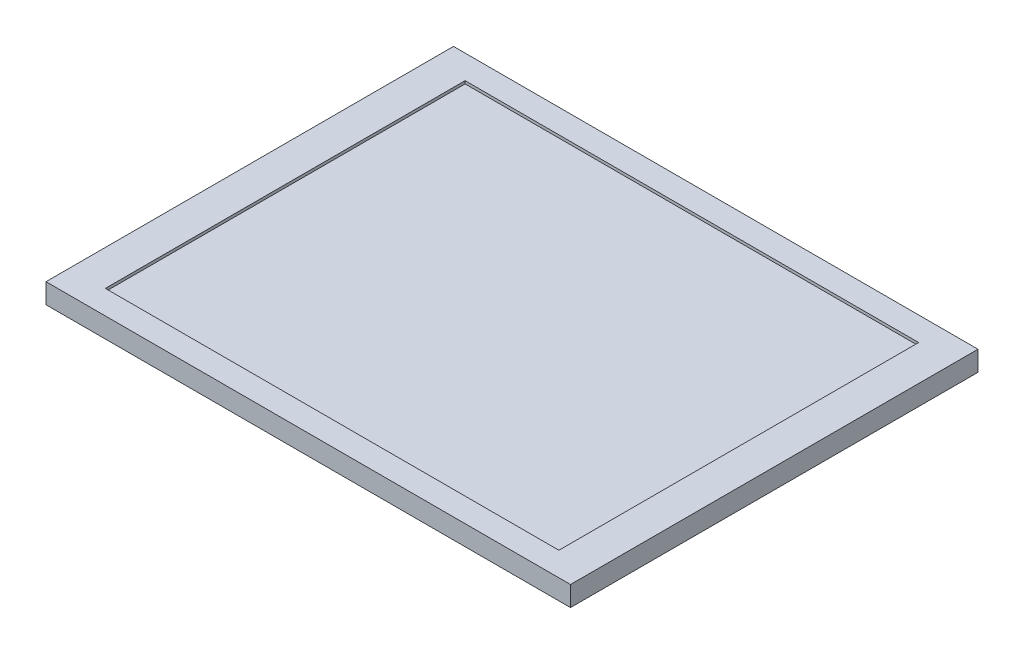
from build123d import *

# Parameters (mm, degrees)
ESBO_O1_W                = 278
ESBO_O1_H                = 216
RESSALTO_EXTRUS_O1_DEPTH = 9.1
ESBO_O2_W                = 240.4
ESBO_O2_H                = 190.7
RESSALTO_EXTRUS_O2_DEPTH = 1.5


with BuildPart() as part:
    # Esboço1 → Ressalto-extrusão1 (new body)
    with BuildSketch(Plane(origin=(0, 0, 0), x_dir=(1, 0, 0), z_dir=(0, 1, 0))):
        Rectangle(ESBO_O1_W, ESBO_O1_H)
    extrude(amount=RESSALTO_EXTRUS_O1_DEPTH)

    # Esboço2 → Ressalto-extrusão2 (add)
    with BuildSketch(Plane(origin=(0, 9.1, 0), x_dir=(1, 0, 0), z_dir=(0, 1, 0))):
        Polygon((-139, 108), (-120.2, 108), (120.2, 108), (139, 108), (139, -108), (120.2, -108), (-120.2, -108), (-139, -108), align=None)
        Rectangle(ESBO_O2_W, ESBO_O2_H, mode=Mode.SUBTRACT)
    extrude(amount=RESSALTO_EXTRUS_O2_DEPTH)


solid = part.part
